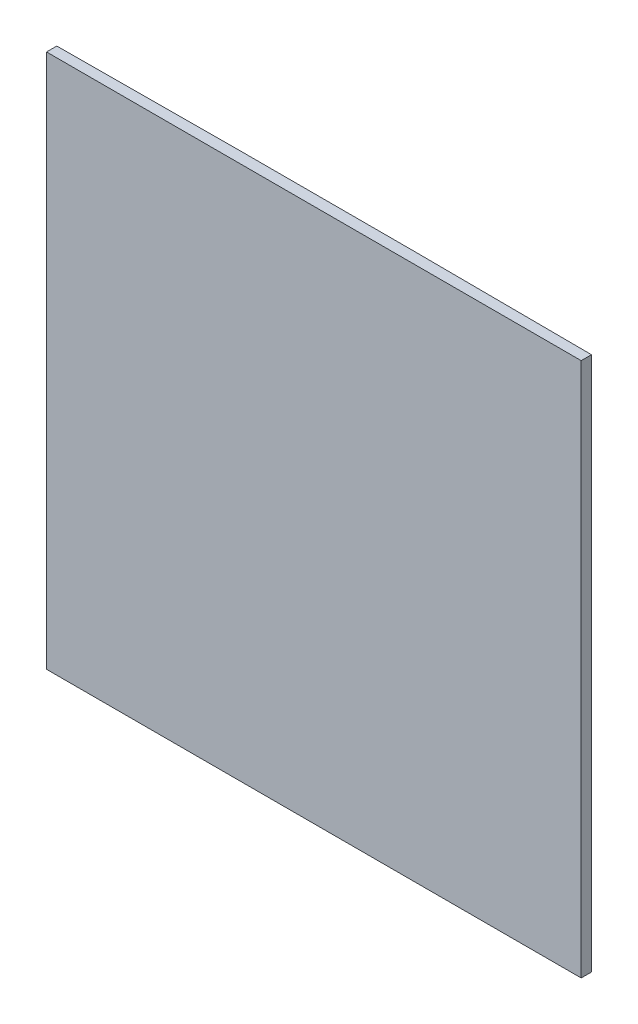
from build123d import *

# Parameters (mm, degrees)
BOSS_EXTRUDE1_DEPTH = 52


with BuildPart() as part:
    # Sketch1 → Boss-Extrude1 (new body)
    with BuildSketch(Plane(origin=(0, 0, 0), x_dir=(1, 0, 0), z_dir=(0, 1, 0))):
        with BuildLine():
            Line((0, 0), (52, 0))
            Line((52, 0), (52, 1))
            ThreePointArc((52, 1), (26, 1.1), (0, 1))
            Line((0, 1), (0, 0))
        make_face()
    extrude(amount=BOSS_EXTRUDE1_DEPTH)


solid = part.part
